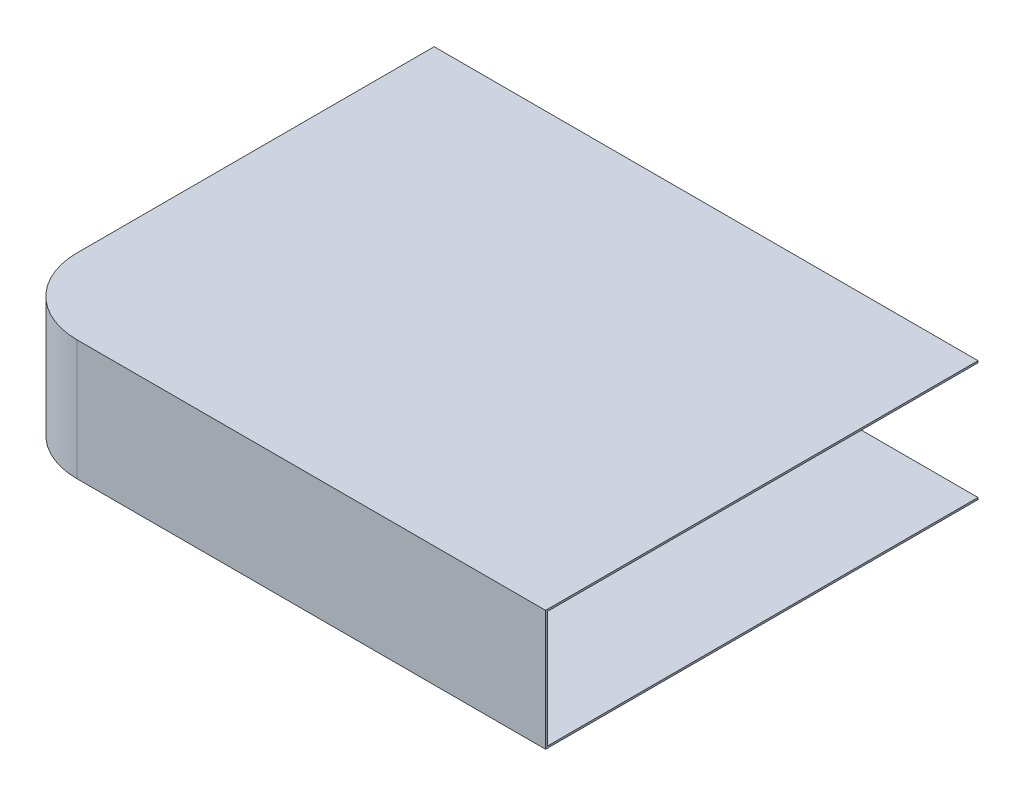
from build123d import *

# Parameters (mm, degrees)
SALIENTE_EXTRUIR1_DEPTH = 32
VACIADO1_T              = -0.5
CROQUIS4_W              = 144.607899287
CROQUIS4_H              = 32
CORTAR_EXTRUIR2_DEPTH   = 3


with BuildPart() as part:
    # Croquis1 → Saliente-Extruir1 (new body)
    with BuildSketch(Plane(origin=(0, 0, 0), x_dir=(1, 0, 0), z_dir=(0, 1, 0))):
        with BuildLine():
            Line((20, 0), (144.607899287, 0))
            Line((144.607899287, 0), (144.607899287, 117.986152898))
            Line((144.607899287, 117.986152898), (0, 117.986152898))
            Line((0, 117.986152898), (0, 20))
            ThreePointArc((0, 20), (5.857864376, 5.857864376), (20, 0))
        make_face()
    extrude(amount=SALIENTE_EXTRUIR1_DEPTH)

    # Vaciado1
    vaciado1_openings = [part.faces().sort_by_distance(p)[0] for p in [
        (144.607899287, 16, -58.993076449),
    ]]
    offset(amount=VACIADO1_T, openings=vaciado1_openings, kind=Kind.INTERSECTION)

    # Croquis4 → Cortar-Extruir2 (cut)
    with BuildSketch(Plane(origin=(0, 0, -117.986152898), x_dir=(-1, 0, 0), z_dir=(0, 0, -1))):
        with Locations((-72.303949644, 16)):
            Rectangle(CROQUIS4_W, CROQUIS4_H)
    extrude(amount=-CORTAR_EXTRUIR2_DEPTH, mode=Mode.SUBTRACT)


solid = part.part
